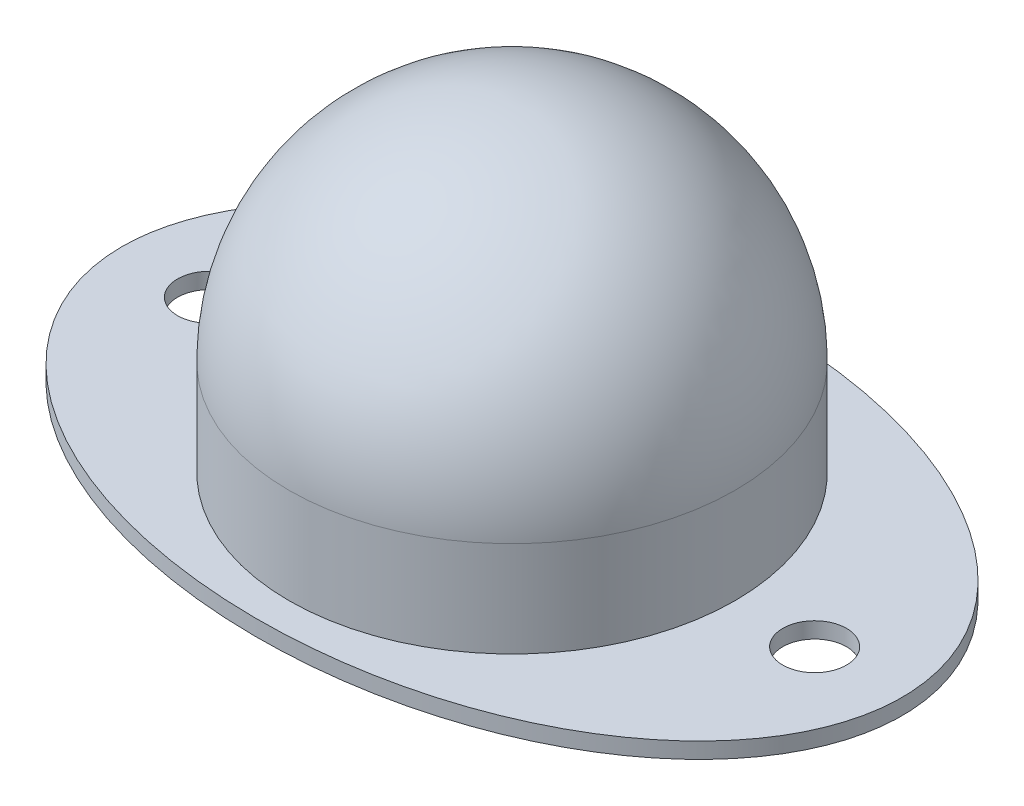
from build123d import *

# Parameters (mm, degrees)
SKETCH1_RX           = 24.5
SKETCH1_RY           = 16
BASE_DEPTH           = 1
SKETCH2_R            = 14
SUPORTE_ESFERA_DEPTH = 20
FILLET1_R            = 14
SKETCH3_R            = 2
FUROS_BASE_DEPTH     = 2


with BuildPart() as part:
    # Sketch1 → Base (new body)
    with BuildSketch(Plane(origin=(0, 0, 0), x_dir=(1, 0, 0), z_dir=(0, 1, 0))):
        with Locations(Location((0, 0), (0, 0, 180))):
            Ellipse(SKETCH1_RX, SKETCH1_RY)
    extrude(amount=BASE_DEPTH)

    # Sketch2 → Suporte-esfera (add)
    with BuildSketch(Plane(origin=(0, 1, 0), x_dir=(1, 0, 0), z_dir=(0, 1, 0))):
        Circle(SKETCH2_R)
    extrude(amount=SUPORTE_ESFERA_DEPTH)

    # Fillet1
    fillet1_edges = [part.edges().sort_by_distance(p)[0] for p in [
        (-14, 21, 0),
    ]]
    fillet(fillet1_edges, radius=FILLET1_R)

    # Sketch3 → Furos-base (cut, through all)
    with BuildSketch(Plane(origin=(0, 1, 0), x_dir=(1, 0, 0), z_dir=(0, 1, 0))):
        with Locations((-19, 0)):
            Circle(SKETCH3_R)
        with Locations((19, 0)):
            Circle(SKETCH3_R)
    extrude(amount=-FUROS_BASE_DEPTH, mode=Mode.SUBTRACT)


solid = part.part
